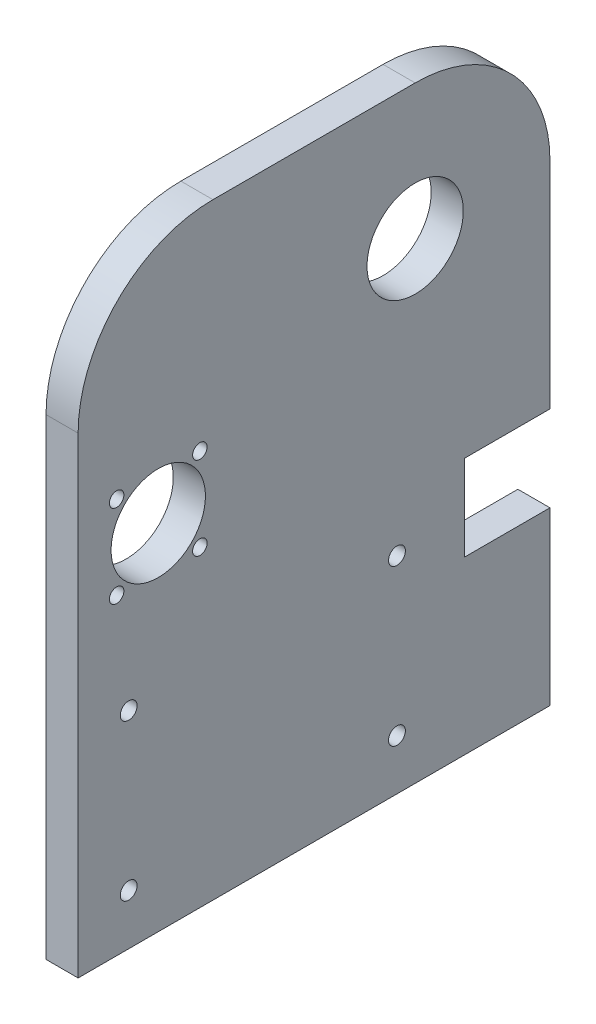
from build123d import *

# Parameters (mm, degrees)
SKETCH1_W             = 9.525
SKETCH1_H             = 140
BOSS_EXTRUDE1_DEPTH   = 90
SKETCH3_R             = 14.29
SKETCH3_R_2           = 2.15
SKETCH3_R_3           = 14
CUT_EXTRUDE2_DEPTH    = 28.575
SKETCH5_W             = 25.4
SKETCH5_H             = 25.4
CUT_EXTRUDE4_DEPTH    = 115.414708954
M6_TAPPED_HOLE1_D     = 5
M6_TAPPED_HOLE1_DEPTH = 10
M6_TAPPED_HOLE1_TIP   = 1.502151548
M6_TAPPED_HOLE2_D     = 5
FILLET1_R             = 40


with BuildPart() as part:
    # Sketch1 → Boss-Extrude1 (new, symmetric)
    with BuildSketch(Plane(origin=(0, 0, 0), x_dir=(1, 0, 0), z_dir=(0, 1, 0))):
        Rectangle(SKETCH1_W, SKETCH1_H)
    extrude(amount=BOSS_EXTRUDE1_DEPTH, both=True)

    # Sketch3 → Cut-Extrude2 (cut)
    with BuildSketch(Plane.ZY.offset(4.7625)):
        with Locations((-30, 50)):
            Circle(SKETCH3_R)
        with Locations((33.881108209, 27.347852166)):
            Circle(SKETCH3_R_2)
        with Locations((58.576812542, 27.347852166)):
            Circle(SKETCH3_R_2)
        with Locations((33.881108209, 2.652147834)):
            Circle(SKETCH3_R_2)
        with Locations((58.576812542, 2.652147834)):
            Circle(SKETCH3_R_2)
        with Locations((46.228960376, 15)):
            Circle(SKETCH3_R_3)
    extrude(amount=-CUT_EXTRUDE2_DEPTH, mode=Mode.SUBTRACT)

    # Sketch5 → Cut-Extrude4 (cut, through all)
    with BuildSketch(Plane.ZY.offset(4.7625)):
        with Locations((-57.3, -26.4746)):
            Rectangle(SKETCH5_W, SKETCH5_H)
    extrude(amount=-CUT_EXTRUDE4_DEPTH, mode=Mode.SUBTRACT)

    # M6 Tapped Hole1
    with Locations(Plane(origin=(0, 0, -44.6), x_dir=(-1, 0, 0), z_dir=(0, 0, -1))):
        with Locations((0, -26.4746)):
            Hole(M6_TAPPED_HOLE1_D / 2, depth=M6_TAPPED_HOLE1_DEPTH)
            with Locations((0, 0, -(M6_TAPPED_HOLE1_DEPTH + M6_TAPPED_HOLE1_TIP / 2))):  # 118° drill point
                Cone(0, M6_TAPPED_HOLE1_D / 2, M6_TAPPED_HOLE1_TIP, mode=Mode.SUBTRACT)

    # M6 Tapped Hole2 (through all)
    with Locations(Plane.ZY.offset(4.7625)):
        with Locations((-24.6, -28.7746), (55, -28.7746), (-24.6, -75), (55, -75)):
            Hole(M6_TAPPED_HOLE2_D / 2)

    # Fillet1
    fillet1_edges = [part.edges().sort_by_distance(p)[0] for p in [
        (0, 90, 70),
        (0, 90, -70),
    ]]
    fillet(fillet1_edges, radius=FILLET1_R)


solid = part.part
